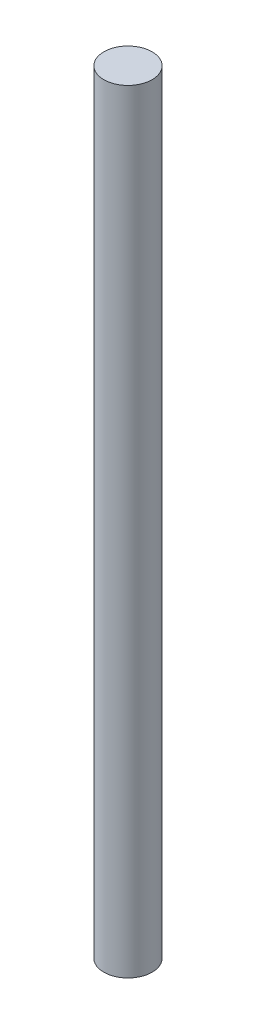
from build123d import *

# Parameters (mm, degrees)
SKETCH1_R           = 1.5875
BOSS_EXTRUDE1_DEPTH = 50.8


with BuildPart() as part:
    # Sketch1 → Boss-Extrude1 (new body)
    with BuildSketch(Plane(origin=(0, 0, 0), x_dir=(1, 0, 0), z_dir=(0, 1, 0))):
        Circle(SKETCH1_R)
    extrude(amount=BOSS_EXTRUDE1_DEPTH)


solid = part.part
